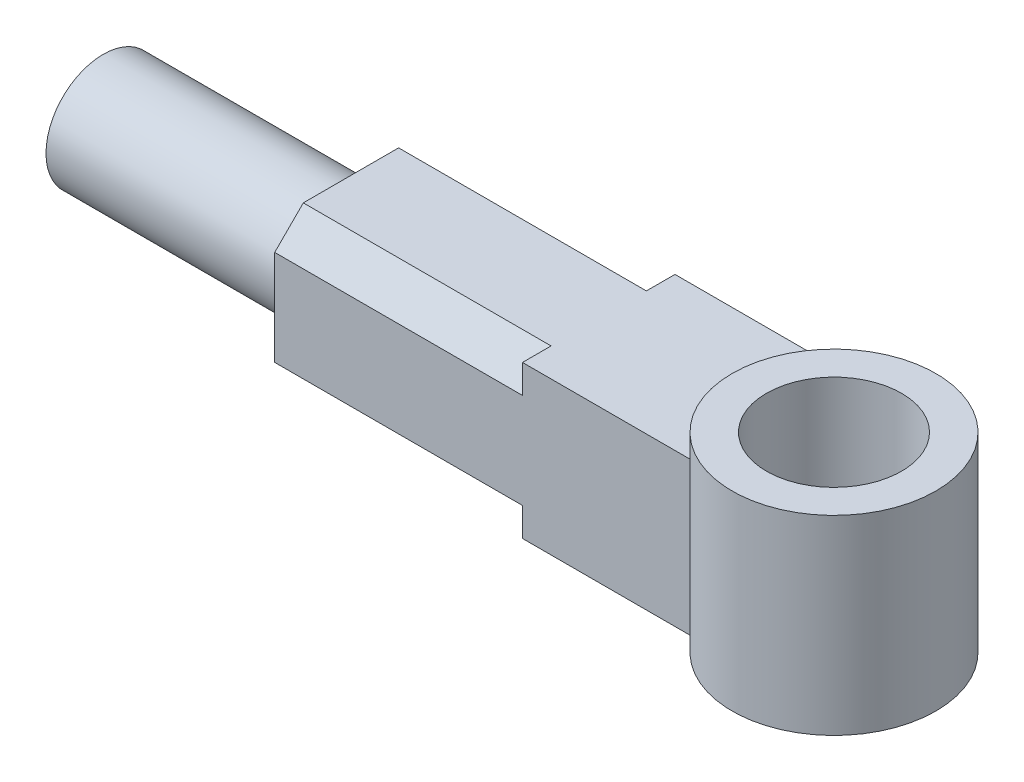
from build123d import *

# Parameters (mm, degrees)
BOSS_EXTRUDE1_DEPTH      = 20
SKETCH2_R                = 26.722222222
SKETCH2_R_2              = 17.722222222
BOSS_EXTRUDE2_DEPTH      = 20
CUT_EXTRUDE1_DEPTH       = 65
SKETCH4_R                = 15
BOSS_EXTRUDE3_DEPTH      = 65
CIRPATTERN1_COUNT        = 4
SKETCH5_W                = 98.755733185
SKETCH5_H                = 100
CUT_EXTRUDE2_DEPTH       = 216.315330002
CUT_EXTRUDE2_DEPTH_BACK  = 216.315330002
MOVE_FACE1_BY            = 9
SKETCH6_R                = 26.722222222
SKETCH6_R_2              = 17.722222222
BOSS_EXTRUDE4_DEPTH      = 5
BOSS_EXTRUDE4_DEPTH_BACK = 45


with BuildPart() as part:
    # Sketch1 → Boss-Extrude1 (new, symmetric)
    with BuildSketch(Plane.XY):
        with BuildLine():
            Line((-140.311288741, 0), (-45, 0))
            ThreePointArc((-45, 0), (-43.812144397, 10.271124735), (-40.311288741, 20))
            Line((-40.311288741, 20), (-140.311288741, 20))
            Line((-140.311288741, 20), (-140.311288741, 0))
        make_face()
        with BuildLine():
            ThreePointArc((-40.311288741, -20), (-43.812144397, -10.271124735), (-45, 0))
            Line((-45, 0), (-140.311288741, 0))
            Line((-140.311288741, 0), (-140.311288741, -20))
            Line((-140.311288741, -20), (-40.311288741, -20))
        make_face()
        with BuildLine():
            ThreePointArc((-25, 0), (-17.67766953, 17.67766953), (0, 25))
            Line((0, 25), (9, 25))
            Line((9, 25), (9, 45))
            Line((9, 45), (0, 45))
            ThreePointArc((0, 45), (-23.717082451, 38.242646352), (-40.311288741, 20))
            ThreePointArc((-40.311288741, 20), (-43.812144397, 10.271124735), (-45, 0))
            Line((-45, 0), (-25, 0))
        make_face()
        with BuildLine():
            ThreePointArc((0, -25), (-17.67766953, -17.67766953), (-25, 0))
            Line((-25, 0), (-45, 0))
            ThreePointArc((-45, 0), (-43.812144397, -10.271124735), (-40.311288741, -20))
            ThreePointArc((-40.311288741, -20), (-23.717082451, -38.242646352), (0, -45))
            Line((0, -45), (9, -45))
            Line((9, -45), (9, -25))
            Line((9, -25), (0, -25))
        make_face()
    extrude(amount=BOSS_EXTRUDE1_DEPTH, both=True)

    # Sketch2 → Boss-Extrude2 (add)
    with BuildSketch(Plane(origin=(0, 45, 0), x_dir=(1, 0, 0), z_dir=(0, 1, 0))):
        with Locations((26.722222222, 0)):
            Circle(SKETCH2_R)
        with Locations(Location((26.722222222, 0, 0), (0, 0, 270))):
            Circle(SKETCH2_R_2, mode=Mode.SUBTRACT)
    boss_extrude2 = extrude(amount=-BOSS_EXTRUDE2_DEPTH)

    # Mirror1: Boss-Extrude2 across plane
    add(boss_extrude2.mirror(Plane.ZX))

    # Sketch3 → Cut-Extrude1 (cut)
    with BuildSketch(Plane.ZY.offset(140.311288741)):
        Polygon((-12.5, 20), (-20, 20), (-20, 12.5), align=None)
    cut_extrude1 = extrude(amount=-CUT_EXTRUDE1_DEPTH, mode=Mode.SUBTRACT)

    # Sketch4 → Boss-Extrude3 (add)
    with BuildSketch(Plane.ZY.offset(140.311288741)):
        with Locations(Location((0, 0, 0), (0, 0, 180))):
            Circle(SKETCH4_R)
    extrude(amount=BOSS_EXTRUDE3_DEPTH)

    # CirPattern1: Cut-Extrude1 ×4 about axis
    cirpattern1_axis = Axis((0, 0, 0), (1, 0, 0))
    for i in range(1, CIRPATTERN1_COUNT):
        add(cut_extrude1.rotate(cirpattern1_axis, i * 360 / CIRPATTERN1_COUNT), mode=Mode.SUBTRACT)

    # Sketch5 → Cut-Extrude2 (cut, two sides)
    with BuildSketch(Plane.XY.offset(20)) as cut_extrude2_sk:
        with Locations((9.066577851, 0)):
            Rectangle(SKETCH5_W, SKETCH5_H)
    extrude(amount=CUT_EXTRUDE2_DEPTH, mode=Mode.SUBTRACT)
    extrude(cut_extrude2_sk.sketch, amount=-CUT_EXTRUDE2_DEPTH_BACK, mode=Mode.SUBTRACT)

    # Move Face1: a face moved outward by 9.0
    extrude(part.faces().sort_by_distance((-40.311288741, 0, 0))[0], amount=MOVE_FACE1_BY, dir=(1, 0, 0))

    # Sketch6 → Boss-Extrude4 (add, two sides)
    with BuildSketch(Plane(origin=(0, 20, 0), x_dir=(1, 0, 0), z_dir=(0, 1, 0))) as boss_extrude4_sk:
        with Locations(Location((-13.589066519, 0, 0), (0, 0, 180))):
            Circle(SKETCH6_R)
        with Locations(Location((-13.589066519, 0, 0), (0, 0, 180))):
            Circle(SKETCH6_R_2, mode=Mode.SUBTRACT)
    extrude(amount=BOSS_EXTRUDE4_DEPTH)
    extrude(boss_extrude4_sk.sketch, amount=-BOSS_EXTRUDE4_DEPTH_BACK)


solid = part.part
